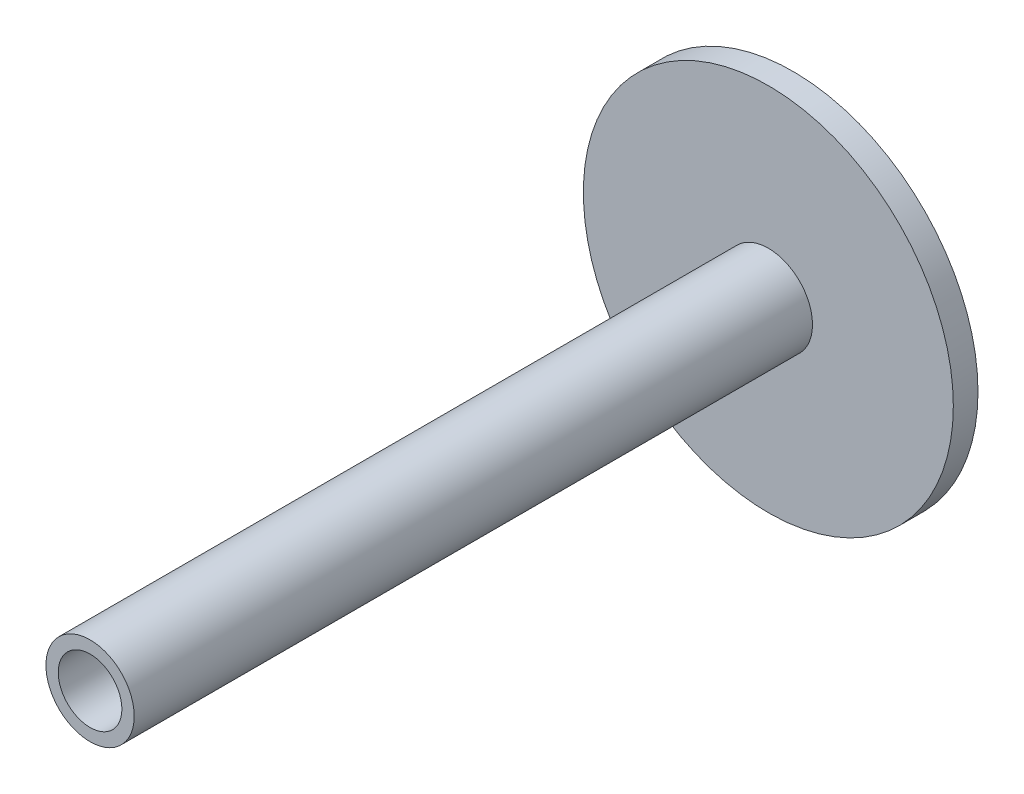
from build123d import *

# Parameters (mm, degrees)
SKETCH1_R           = 15
BOSS_EXTRUDE1_DEPTH = 2
SKETCH2_R           = 3.58
SKETCH2_R_2         = 2.58
BOSS_EXTRUDE2_DEPTH = 55
SKETCH3_R           = 2.58
CUT_EXTRUDE1_DEPTH  = 55


with BuildPart() as part:
    # Sketch1 → Boss-Extrude1 (new body)
    with BuildSketch(Plane.XY):
        Circle(SKETCH1_R)
    extrude(amount=BOSS_EXTRUDE1_DEPTH)

    # Sketch2 → Boss-Extrude2 (add)
    with BuildSketch(Plane.XY.offset(2)):
        Circle(SKETCH2_R)
        Circle(SKETCH2_R_2, mode=Mode.SUBTRACT)
    extrude(amount=BOSS_EXTRUDE2_DEPTH)

    # Sketch3 → Cut-Extrude1 (cut)
    with BuildSketch(Plane.XY.offset(2)):
        Circle(SKETCH3_R)
    extrude(amount=-CUT_EXTRUDE1_DEPTH, mode=Mode.SUBTRACT)


solid = part.part
